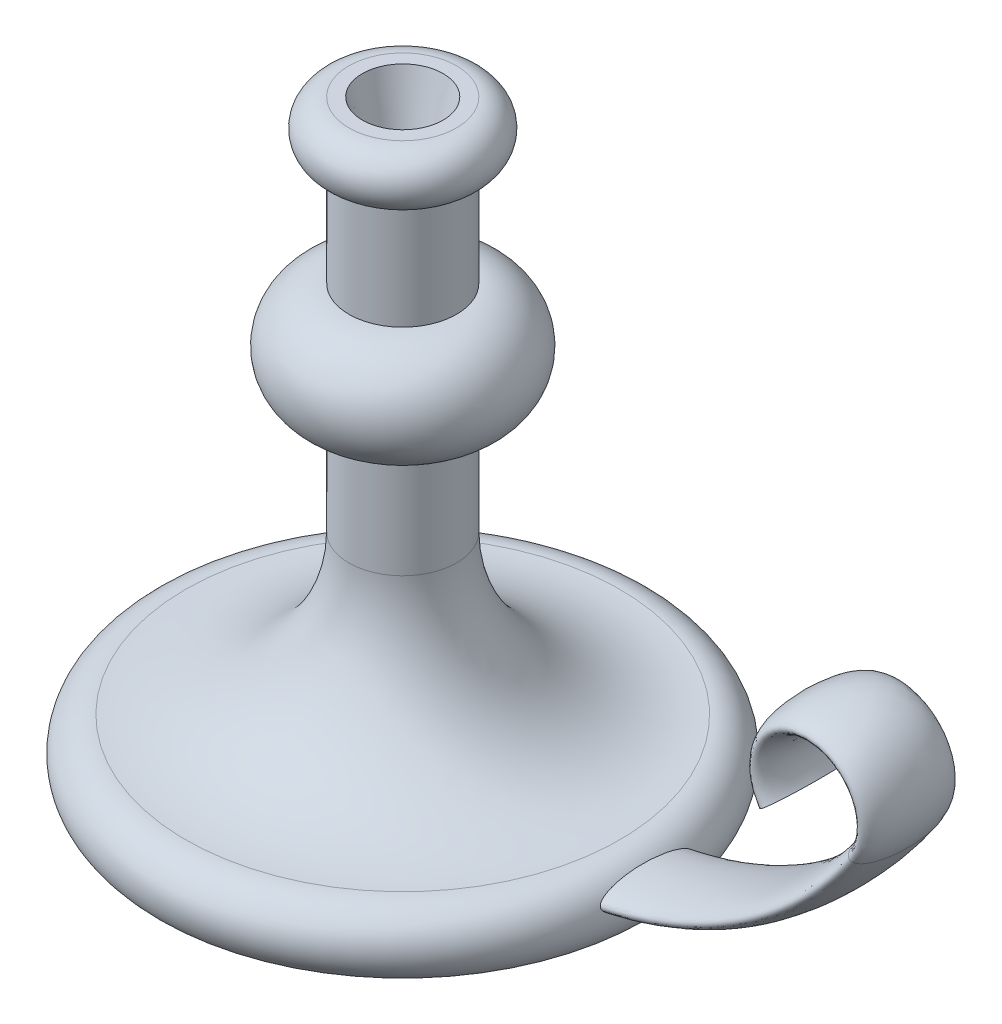
from build123d import *

# Parameters (mm, degrees)
SKETCH3_RX         = 17.5
SKETCH3_RY         = 5
SKETCH9_R          = 15
CUT_EXTRUDE3_DEPTH = 25
CUT_EXTRUDE3_TAPER = 15


with BuildPart() as part:
    # Sketch1 → Revolve1 (revolve)
    with BuildSketch(Plane.XY):
        with BuildLine():
            Line((0, 220), (0, 0))
            Line((0, 0), (90, 0))
            ThreePointArc((90, 0), (92.47578021, 13.756891061), (80.649442473, 21.208016819))
            ThreePointArc((80.649442473, 21.208016819), (37.879865469, 37.765972964), (20, 80))
            Line((20, 80), (20, 120))
            ThreePointArc((20, 120), (40, 140), (20, 160))
            Line((20, 160), (20, 200))
            ThreePointArc((20, 200), (30, 210), (20, 220))
            Line((20, 220), (0, 220))
        make_face()
    revolve(axis=Axis((0, 220, 0), (0, -1, 0)))

    # Sweep1: sweep along a path in Sketch2
    with BuildLine(Plane.XY) as sweep1_path:
        Line((0, 10), (60, 10))
        ThreePointArc((60, 10), (129.821200219, 27.240819526), (183.592070943, 75))
        ThreePointArc((183.592070943, 75), (167.113128151, 106.333333333), (150.634185358, 75))
    # Sketch3 → Sweep1 (sweep)
    with BuildSketch(Plane(origin=(0, 0, 0), x_dir=(0, 0, -1), z_dir=(1, 0, 0))):
        with Locations((0, 10)):
            Ellipse(SKETCH3_RX, SKETCH3_RY)
    sweep(path=sweep1_path.line)

    # Sketch9 → Cut-Extrude3 (cut)
    with BuildSketch(Plane(origin=(0, 220, 0), x_dir=(1, 0, 0), z_dir=(0, 1, 0))):
        Circle(SKETCH9_R)
    extrude(amount=-CUT_EXTRUDE3_DEPTH, taper=CUT_EXTRUDE3_TAPER, mode=Mode.SUBTRACT)


solid = part.part
